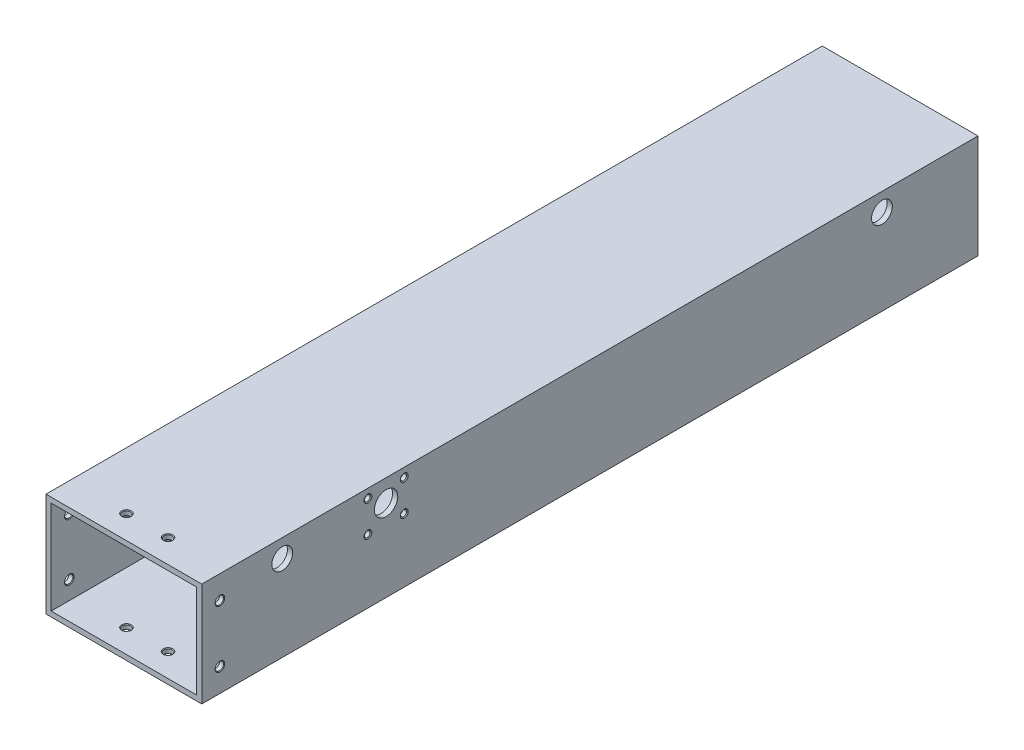
from build123d import *

# Parameters (mm, degrees)
SKETCH_1_W                   = 60
SKETCH_1_H                   = 40
SKETCH_1_W_2                 = 56
SKETCH_1_H_2                 = 36
EXTRUDE_1_DEPTH              = 299
HOLE_WIZARD_M31_AT_2_COUNT   = 2
HOLE_WIZARD_M31_AT_2_PITCH   = 22
HOLE_WIZARD_M32_AT_2_COUNT   = 2
HOLE_WIZARD_M32_AT_2_PITCH   = 22
HOLE_WIZARD_M33_AT_2_COUNT   = 2
HOLE_WIZARD_M33_AT_2_PITCH   = 16
HOLE_WIZARD_M34_AT_2_COUNT   = 2
HOLE_WIZARD_M34_AT_2_PITCH   = 16
CUT_EXTRUDE_4347_REACH       = 42
SKETCH_12_R                  = 4
CUT_EXTRUDE_3_REACH          = 62
SKETCH_15_R                  = 4
SKETCH_15_R_2                = 4.5
HOLE_WIZARD_4_401_AT_2_COUNT = 2
HOLE_WIZARD_4_401_AT_2_PITCH = 12
HOLE_WIZARD_4_401_AT_3_COUNT = 2
HOLE_WIZARD_4_401_AT_3_PITCH = 18.439088915
HOLE_WIZARD_4_401_AT_4_COUNT = 2
HOLE_WIZARD_4_401_AT_4_PITCH = 14


with BuildPart() as part:
    # Эскиз1 → Вытянуть1 (new body)
    with BuildSketch(Plane.XY):
        Rectangle(SKETCH_1_W, SKETCH_1_H)
        Rectangle(SKETCH_1_W_2, SKETCH_1_H_2, mode=Mode.SUBTRACT)
    extrude(amount=EXTRUDE_1_DEPTH)

    # Эскиз2 → Hole Wizard M31 (revolve, cut)
    with BuildSketch(Plane(origin=(-30, 11, 292), x_dir=(0, 0, 1), z_dir=(0, 1, 0))):
        Polygon((0, 0), (0, 2), (1.85, 2), (1.6, 1.75), (1.6, 0.25), (1.85, 0), align=None)
    hole_wizard_m31 = revolve(axis=Axis((-36.35, 11, 292), (1, 0, 0)), mode=Mode.SUBTRACT)

    # Hole Wizard M31 at 2: Hole Wizard M31 ×2
    with Locations(*[(0, -i * HOLE_WIZARD_M31_AT_2_PITCH, 0) for i in range(1, HOLE_WIZARD_M31_AT_2_COUNT)]):
        add(hole_wizard_m31, mode=Mode.SUBTRACT)

    # Эскиз4 → Отверстие с зазором M32 (revolve, cut)
    with BuildSketch(Plane(origin=(30, -11, 292), x_dir=(0, 0, -1), z_dir=(0, 1, 0))):
        Polygon((0, 0), (0, 2), (1.85, 2), (1.6, 1.75), (1.6, 0.25), (1.85, 0), align=None)
    hole_wizard_m32 = revolve(axis=Axis((36.35, -11, 292), (-1, 0, 0)), mode=Mode.SUBTRACT)

    # Отверстие с зазором M32 at 2: Отверстие с зазором M32 ×2
    with Locations(*[(0, i * HOLE_WIZARD_M32_AT_2_PITCH, 0) for i in range(1, HOLE_WIZARD_M32_AT_2_COUNT)]):
        add(hole_wizard_m32, mode=Mode.SUBTRACT)

    # Эскиз6 → Отверстие с зазором M33 (revolve, cut)
    with BuildSketch(Plane(origin=(-8, -20, 290), x_dir=(0, 0, -1), z_dir=(1, 0, 0))):
        Polygon((0, 0), (0, 2), (1.85, 2), (1.6, 1.75), (1.6, 0.25), (1.85, 0), align=None)
    hole_wizard_m33 = revolve(axis=Axis((-8, -26.35, 290), (0, 1, 0)), mode=Mode.SUBTRACT)

    # Отверстие с зазором M33 at 2: Отверстие с зазором M33 ×2
    with Locations(*[(i * HOLE_WIZARD_M33_AT_2_PITCH, 0, 0) for i in range(1, HOLE_WIZARD_M33_AT_2_COUNT)]):
        add(hole_wizard_m33, mode=Mode.SUBTRACT)

    # Эскиз8 → Отверстие с зазором M34 (revolve, cut)
    with BuildSketch(Plane(origin=(8, 20, 290), x_dir=(0, 0, 1), z_dir=(1, 0, 0))):
        Polygon((0, 0), (0, 2), (1.85, 2), (1.6, 1.75), (1.6, 0.25), (1.85, 0), align=None)
    hole_wizard_m34 = revolve(axis=Axis((8, 26.35, 290), (0, -1, 0)), mode=Mode.SUBTRACT)

    # Отверстие с зазором M34 at 2: Отверстие с зазором M34 ×2
    with Locations(*[(-i * HOLE_WIZARD_M34_AT_2_PITCH, 0, 0) for i in range(1, HOLE_WIZARD_M34_AT_2_COUNT)]):
        add(hole_wizard_m34, mode=Mode.SUBTRACT)

    # Эскиз12 → Cut-Extrude 4347 (cut, up to next)
    with BuildSketch(Plane(origin=(0, -20, 0), x_dir=(1, 0, 0), z_dir=(0, 1, 0)), mode=Mode.PRIVATE) as cut_extrude_4347_sk1:
        with Locations((19, -240.5)):
            Circle(SKETCH_12_R)
    cut_extrude_4347_tool1 = extrude(cut_extrude_4347_sk1.sketch, amount=CUT_EXTRUDE_4347_REACH, mode=Mode.PRIVATE) & part.part
    add(cut_extrude_4347_tool1.solids().sort_by_distance((19, -20, 240.5))[0], mode=Mode.SUBTRACT)
    # Эскиз12 → Cut-Extrude 4347 (cut, up to next)
    with BuildSketch(Plane(origin=(0, -20, 0), x_dir=(1, 0, 0), z_dir=(0, 1, 0)), mode=Mode.PRIVATE) as cut_extrude_4347_sk2:
        with Locations((12, -35)):
            Circle(SKETCH_12_R)
    cut_extrude_4347_tool2 = extrude(cut_extrude_4347_sk2.sketch, amount=CUT_EXTRUDE_4347_REACH, mode=Mode.PRIVATE) & part.part
    add(cut_extrude_4347_tool2.solids().sort_by_distance((12, -20, 35))[0], mode=Mode.SUBTRACT)

    # Эскиз15 → Вырез-Вытянуть3 (cut, up to next)
    with BuildSketch(Plane(origin=(30, 0, 0), x_dir=(0, 0, -1), z_dir=(1, 0, 0)), mode=Mode.PRIVATE) as cut_extrude_3_sk1:
        with Locations((-37, 13)):
            Circle(SKETCH_15_R)
    cut_extrude_3_tool1 = extrude(cut_extrude_3_sk1.sketch, amount=-CUT_EXTRUDE_3_REACH, mode=Mode.PRIVATE) & part.part
    add(cut_extrude_3_tool1.solids().sort_by_distance((30, 13, 37))[0], mode=Mode.SUBTRACT)
    # Эскиз15 → Вырез-Вытянуть3 (cut, up to next)
    with BuildSketch(Plane(origin=(30, 0, 0), x_dir=(0, 0, -1), z_dir=(1, 0, 0)), mode=Mode.PRIVATE) as cut_extrude_3_sk2:
        with Locations((-268, 13)):
            Circle(SKETCH_15_R)
    cut_extrude_3_tool2 = extrude(cut_extrude_3_sk2.sketch, amount=-CUT_EXTRUDE_3_REACH, mode=Mode.PRIVATE) & part.part
    add(cut_extrude_3_tool2.solids().sort_by_distance((30, 13, 268))[0], mode=Mode.SUBTRACT)
    # Эскиз15 → Вырез-Вытянуть3 (cut, up to next)
    with BuildSketch(Plane(origin=(30, 0, 0), x_dir=(0, 0, -1), z_dir=(1, 0, 0)), mode=Mode.PRIVATE) as cut_extrude_3_sk3:
        with Locations((-228, 11.5)):
            Circle(SKETCH_15_R_2)
    cut_extrude_3_tool3 = extrude(cut_extrude_3_sk3.sketch, amount=-CUT_EXTRUDE_3_REACH, mode=Mode.PRIVATE) & part.part
    add(cut_extrude_3_tool3.solids().sort_by_distance((30, 11.5, 228))[0], mode=Mode.SUBTRACT)

    # Эскиз16 → Отверстие обработанное метчиком #4-401 (revolve, cut)
    with BuildSketch(Plane(origin=(30, 16.5, 235), x_dir=(0, 0, -1), z_dir=(0, 1, 0))):
        Polygon((0, 0), (0, 2), (1.524, 2), (1.1303, 1.724328292), (1.1303, 0.275671708), (1.524, 0), align=None)
    hole_wizard_4_401 = revolve(axis=Axis((36.35, 16.5, 235), (-1, 0, 0)), mode=Mode.SUBTRACT)

    # Отверстие обработанное метчиком #4-401 at 2: Отверстие обработанное метчиком #4-401 ×2
    with Locations(*[(0, -i * HOLE_WIZARD_4_401_AT_2_PITCH, 0) for i in range(1, HOLE_WIZARD_4_401_AT_2_COUNT)]):
        add(hole_wizard_4_401, mode=Mode.SUBTRACT)

    # Отверстие обработанное метчиком #4-401 at 3: Отверстие обработанное метчиком #4-401 ×2
    with Locations(*[Vector(0, -0.650791373, -0.759256602) * (i * HOLE_WIZARD_4_401_AT_3_PITCH) for i in range(1, HOLE_WIZARD_4_401_AT_3_COUNT)]):
        add(hole_wizard_4_401, mode=Mode.SUBTRACT)

    # Отверстие обработанное метчиком #4-401 at 4: Отверстие обработанное метчиком #4-401 ×2
    with Locations(*[(0, 0, -i * HOLE_WIZARD_4_401_AT_4_PITCH) for i in range(1, HOLE_WIZARD_4_401_AT_4_COUNT)]):
        add(hole_wizard_4_401, mode=Mode.SUBTRACT)


solid = part.part
